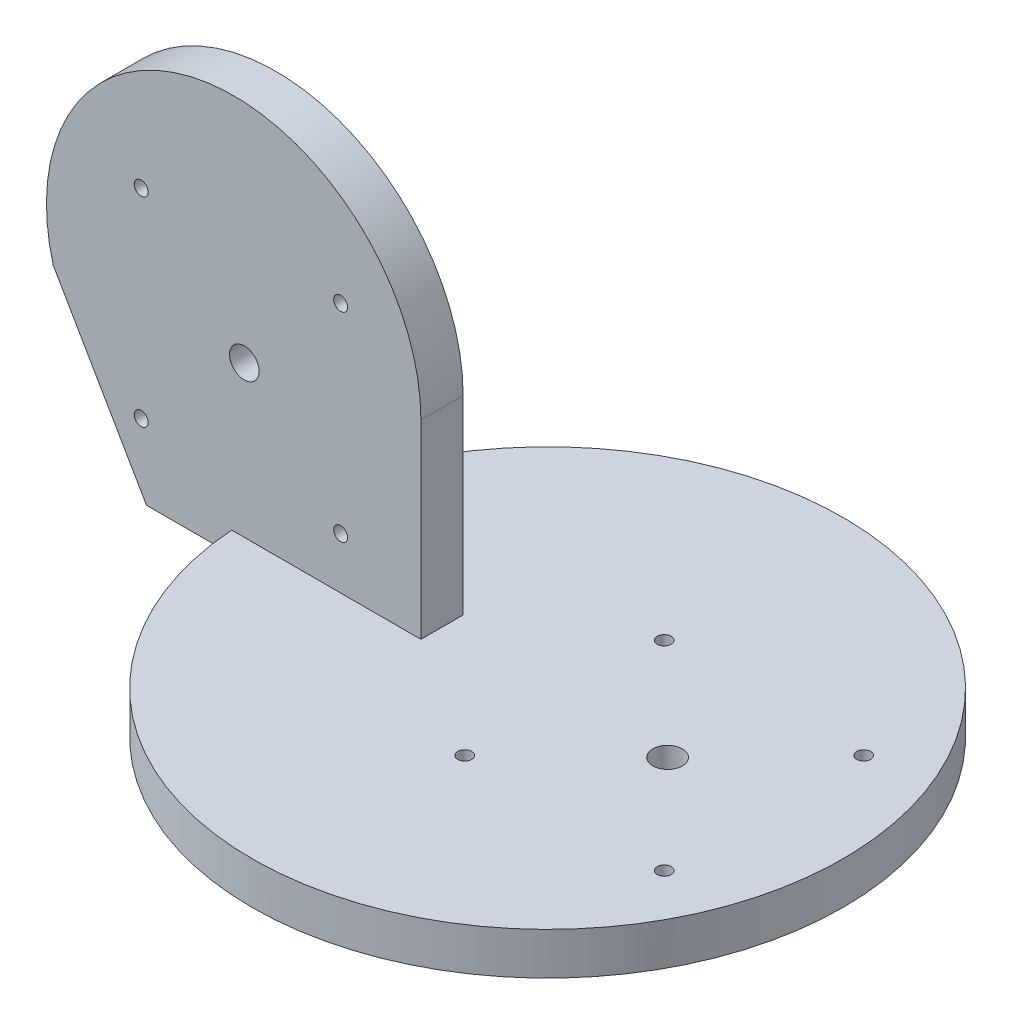
from build123d import *

# Parameters (mm, degrees)
SKETCH1_R                 = 70
BOSS_EXTRUDE1_DEPTH       = 10
SKETCH2_R                 = 65
BOSS_EXTRUDE2_DEPTH       = 3
BOSS_EXTRUDE3_DEPTH       = 5
M4X0_7_TAPPED_HOLE1_D     = 3.3
M4X0_7_TAPPED_HOLE1_DEPTH = 10.1
M4X0_7_TAPPED_HOLE1_TIP   = 0.991420021
M8X1_0_TAPPED_HOLE1_D     = 7
M4X0_7_TAPPED_HOLE3_D     = 3.3
M4X0_7_TAPPED_HOLE3_DEPTH = 10.1
M4X0_7_TAPPED_HOLE3_TIP   = 0.991420021
M8X1_0_TAPPED_HOLE2_D     = 7


with BuildPart() as part:
    # Sketch1 → Boss-Extrude1 (new body)
    with BuildSketch(Plane(origin=(0, 0, 0), x_dir=(1, 0, 0), z_dir=(0, 1, 0))):
        Circle(SKETCH1_R)
    extrude(amount=BOSS_EXTRUDE1_DEPTH)

    # Sketch2 → Boss-Extrude2 (add)
    with BuildSketch(Plane.XZ):
        Circle(SKETCH2_R)
    extrude(amount=BOSS_EXTRUDE2_DEPTH)

    # Sketch3 → Boss-Extrude3 (add, symmetric)
    with BuildSketch(Plane.XY):
        with BuildLine():
            Line((-25, 55), (-25, 5))
            Line((-25, 5), (-90, 5))
            Line((-90, 5), (-112.094257771, 43.204763027))
            ThreePointArc((-112.094257771, 43.204763027), (-75.29730578, 98.944673602), (-25, 55))
        make_face()
    extrude(amount=BOSS_EXTRUDE3_DEPTH, both=True)

    # M4x0.7 Tapped Hole1
    with Locations(Plane(origin=(0, 10, 0), x_dir=(1, 0, 0), z_dir=(0, 1, 0))):
        with Locations((4, 23.622), (51.244, 23.622), (51.244, -23.622), (4, -23.622)):
            Hole(M4X0_7_TAPPED_HOLE1_D / 2, depth=M4X0_7_TAPPED_HOLE1_DEPTH)
            with Locations((0, 0, -(M4X0_7_TAPPED_HOLE1_DEPTH + M4X0_7_TAPPED_HOLE1_TIP / 2))):  # 118° drill point
                Cone(0, M4X0_7_TAPPED_HOLE1_D / 2, M4X0_7_TAPPED_HOLE1_TIP, mode=Mode.SUBTRACT)

    # M8x1.0 Tapped Hole1 (through all)
    with Locations(Plane(origin=(0, 10, 0), x_dir=(1, 0, 0), z_dir=(0, 1, 0))):
        with Locations((28.426798857, 0)):
            Hole(M8X1_0_TAPPED_HOLE1_D / 2)

    # M4x0.7 Tapped Hole3
    with Locations(Plane(origin=(-95.25342131, 45.793176502, 5), x_dir=(1, 0, 0), z_dir=(0, 0, 1))):
        with Locations((4, 23.622), (51.244, 23.622), (51.244, -23.622), (4, -23.622)):
            Hole(M4X0_7_TAPPED_HOLE3_D / 2, depth=M4X0_7_TAPPED_HOLE3_DEPTH)
            with Locations((0, 0, -(M4X0_7_TAPPED_HOLE3_DEPTH + M4X0_7_TAPPED_HOLE3_TIP / 2))):  # 118° drill point
                Cone(0, M4X0_7_TAPPED_HOLE3_D / 2, M4X0_7_TAPPED_HOLE3_TIP, mode=Mode.SUBTRACT)

    # M8x1.0 Tapped Hole2 (through all)
    with Locations(Plane(origin=(-95.25342131, 45.793176502, 5), x_dir=(1, 0, 0), z_dir=(0, 0, 1))):
        with Locations((28.426798857, 0)):
            Hole(M8X1_0_TAPPED_HOLE2_D / 2)


solid = part.part
